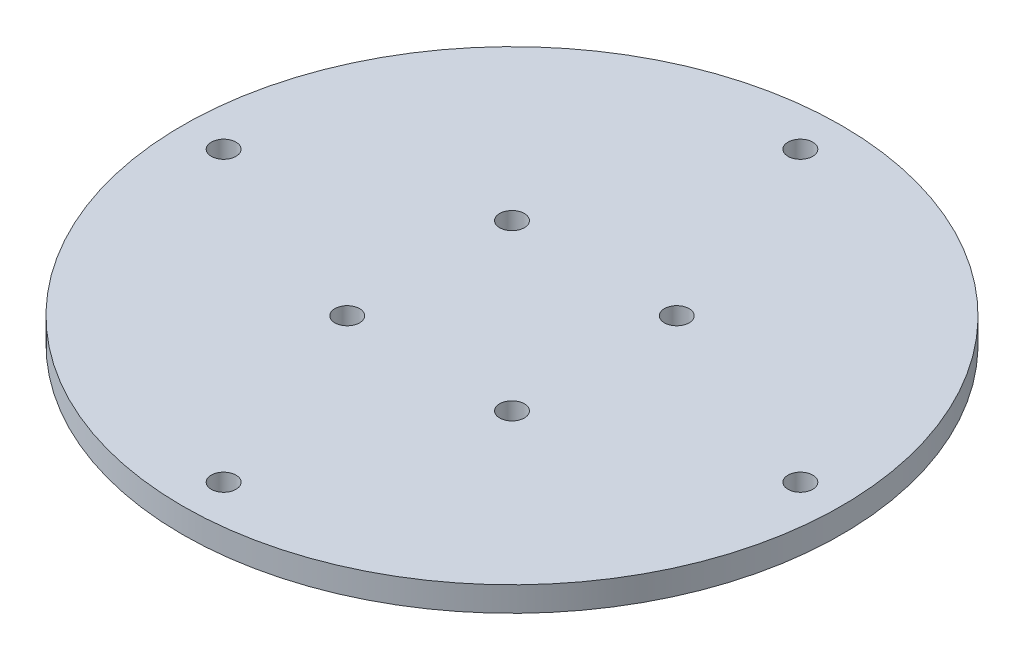
from build123d import *

# Parameters (mm, degrees)
SKETCH1_R           = 40
SKETCH1_R_2         = 1.5
BOSS_EXTRUDE1_DEPTH = 3
SKETCH2_R           = 1.5
CUT_EXTRUDE1_DEPTH  = 3


with BuildPart() as part:
    # Sketch1 → Boss-Extrude1 (new body)
    with BuildSketch(Plane(origin=(0, 0, 0), x_dir=(1, 0, 0), z_dir=(0, 1, 0))):
        Circle(SKETCH1_R)
        with Locations((0, 35)):
            Circle(SKETCH1_R_2, mode=Mode.SUBTRACT)
        with Locations((35, 0)):
            Circle(SKETCH1_R_2, mode=Mode.SUBTRACT)
        with Locations((0, -35)):
            Circle(SKETCH1_R_2, mode=Mode.SUBTRACT)
        with Locations((-35, 0)):
            Circle(SKETCH1_R_2, mode=Mode.SUBTRACT)
    extrude(amount=BOSS_EXTRUDE1_DEPTH)

    # Sketch2 → Cut-Extrude1 (cut)
    with BuildSketch(Plane(origin=(0, 3, 0), x_dir=(1, 0, 0), z_dir=(0, 1, 0))):
        with Locations((10, 10)):
            Circle(SKETCH2_R)
        with Locations((-10, 10)):
            Circle(SKETCH2_R)
        with Locations((-10, -10)):
            Circle(SKETCH2_R)
        with Locations((10, -10)):
            Circle(SKETCH2_R)
    extrude(amount=-CUT_EXTRUDE1_DEPTH, mode=Mode.SUBTRACT)


solid = part.part
